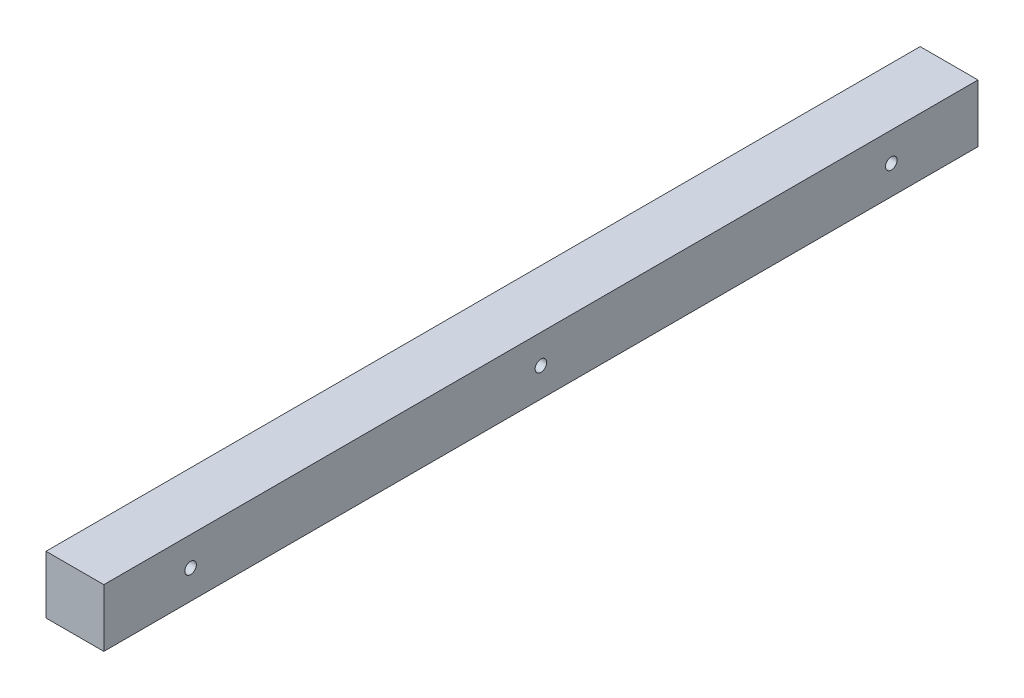
from build123d import *

# Parameters (mm, degrees)
SKETCH1_W           = 20
SKETCH1_H           = 20
BOSS_EXTRUDE1_DEPTH = 302.33
SKETCH2_R           = 2
CUT_EXTRUDE1_DEPTH  = 21


with BuildPart() as part:
    # Sketch1 → Boss-Extrude1 (new body)
    with BuildSketch(Plane.XY):
        with Locations((10, 10)):
            Rectangle(SKETCH1_W, SKETCH1_H)
    extrude(amount=BOSS_EXTRUDE1_DEPTH)

    # Sketch2 → Cut-Extrude1 (cut, through all)
    with BuildSketch(Plane.ZY):
        with Locations((30, 10)):
            Circle(SKETCH2_R)
        with Locations((272.33, 10)):
            Circle(SKETCH2_R)
        with Locations((151.165, 10)):
            Circle(SKETCH2_R)
    extrude(amount=-CUT_EXTRUDE1_DEPTH, mode=Mode.SUBTRACT)


solid = part.part
